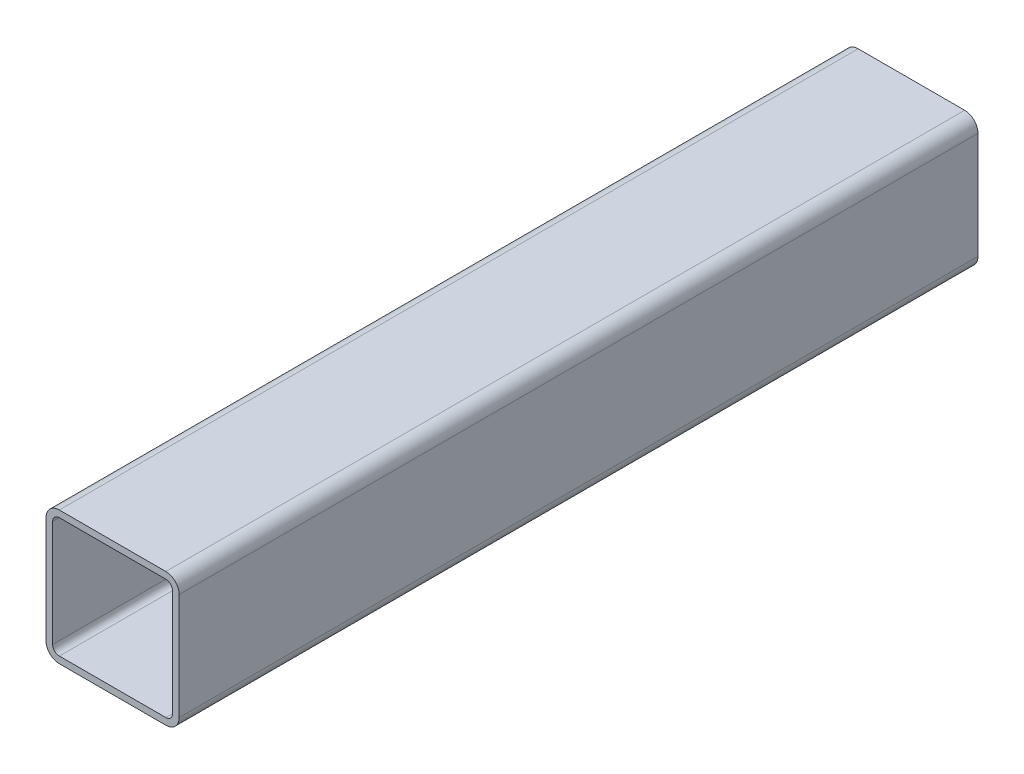
from build123d import *

# Parameters (mm, degrees)
BOSS_EXTRUDE1_DEPTH = 300


with BuildPart() as part:
    # Sketch2 → Boss-Extrude1 (new body, symmetric)
    with BuildSketch(Plane.XY):
        with BuildLine():
            Line((-50, 40), (-50, -40))
            ThreePointArc((-50, -40), (-47.071067812, -47.071067812), (-40, -50))
            Line((-40, -50), (40, -50))
            ThreePointArc((40, -50), (47.071067812, -47.071067812), (50, -40))
            Line((50, -40), (50, 40))
            ThreePointArc((50, 40), (47.071067812, 47.071067812), (40, 50))
            Line((40, 50), (-40, 50))
            ThreePointArc((-40, 50), (-47.071067812, 47.071067812), (-50, 40))
        make_face()
        with BuildLine():
            Line((40, 45), (-40, 45))
            ThreePointArc((-40, 45), (-43.535533906, 43.535533906), (-45, 40))
            Line((-45, 40), (-45, -40))
            ThreePointArc((-45, -40), (-43.535533906, -43.535533906), (-40, -45))
            Line((-40, -45), (40, -45))
            ThreePointArc((40, -45), (43.535533906, -43.535533906), (45, -40))
            Line((45, -40), (45, 40))
            ThreePointArc((45, 40), (43.535533906, 43.535533906), (40, 45))
        make_face(mode=Mode.SUBTRACT)
    extrude(amount=BOSS_EXTRUDE1_DEPTH, both=True)


solid = part.part
